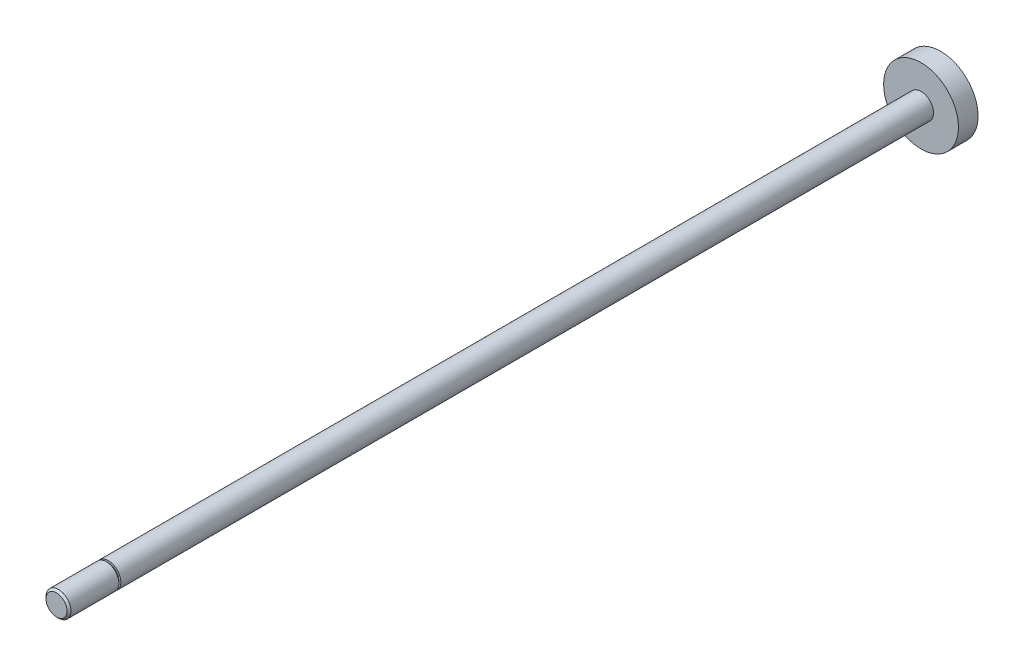
from build123d import *


with BuildPart() as part:
    # Sketch1 → Revolve1 (revolve)
    with BuildSketch(Plane.XZ):
        Polygon((2.675, 146.431), (0, 146.431), (0, -78.7), (9.525, -78.7), (9.525, -73.7), (3.175, -73.7), (3.175, 133.231), (2.675, 133.231), (2.675, 133.731), (3.175, 133.731), (3.175, 145.931), align=None)
    revolve(axis=Axis((0, 0, 146.431), (0, 0, -1)))


solid = part.part
